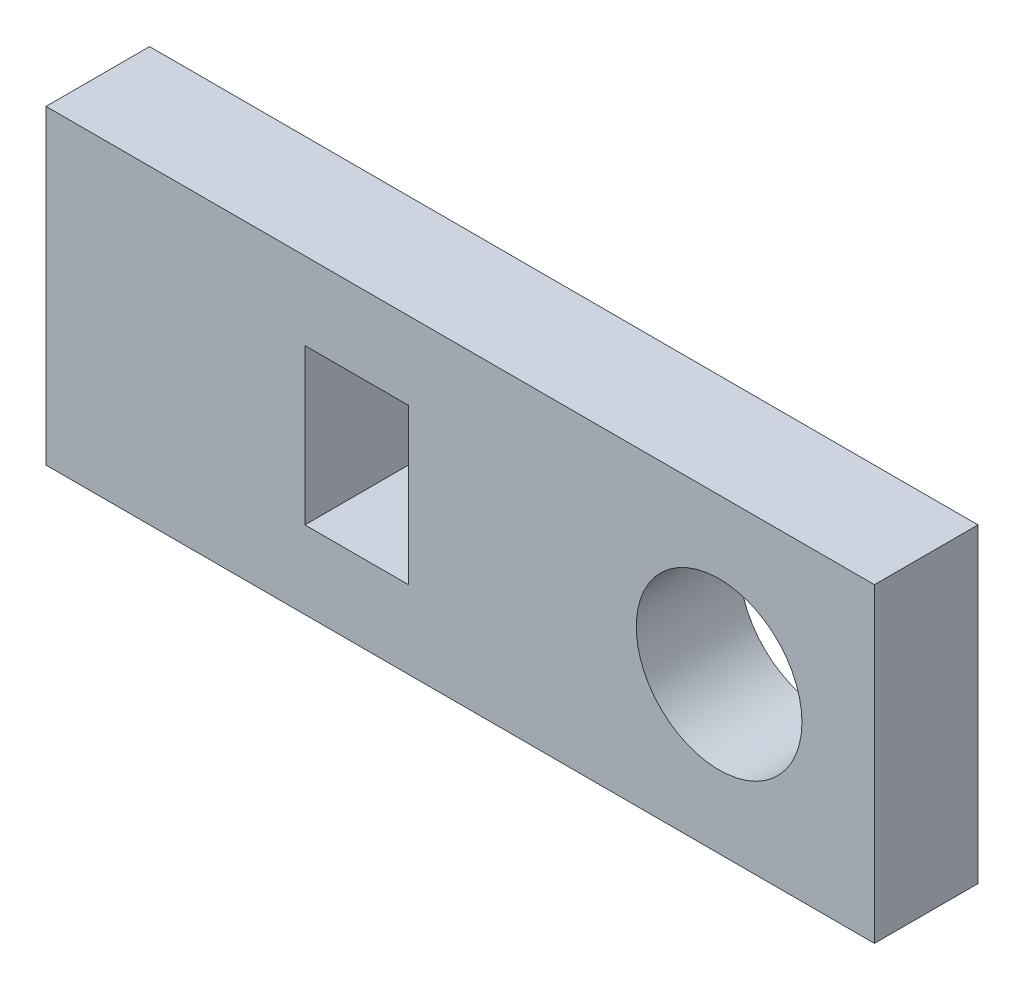
from build123d import *

# Parameters (mm, degrees)
SKETCH1_W           = 40
SKETCH1_H           = 15
SKETCH1_R           = 4
SKETCH1_W_2         = 5
SKETCH1_H_2         = 7.5
BOSS_EXTRUDE1_DEPTH = 5


with BuildPart() as part:
    # Sketch1 → Boss-Extrude1 (new body)
    with BuildSketch(Plane.XY):
        with Locations((20, 7.5)):
            Rectangle(SKETCH1_W, SKETCH1_H)
        with Locations((32.5, 7.5)):
            Circle(SKETCH1_R, mode=Mode.SUBTRACT)
        with Locations((15, 7.5)):
            Rectangle(SKETCH1_W_2, SKETCH1_H_2, mode=Mode.SUBTRACT)
    extrude(amount=BOSS_EXTRUDE1_DEPTH)


solid = part.part
